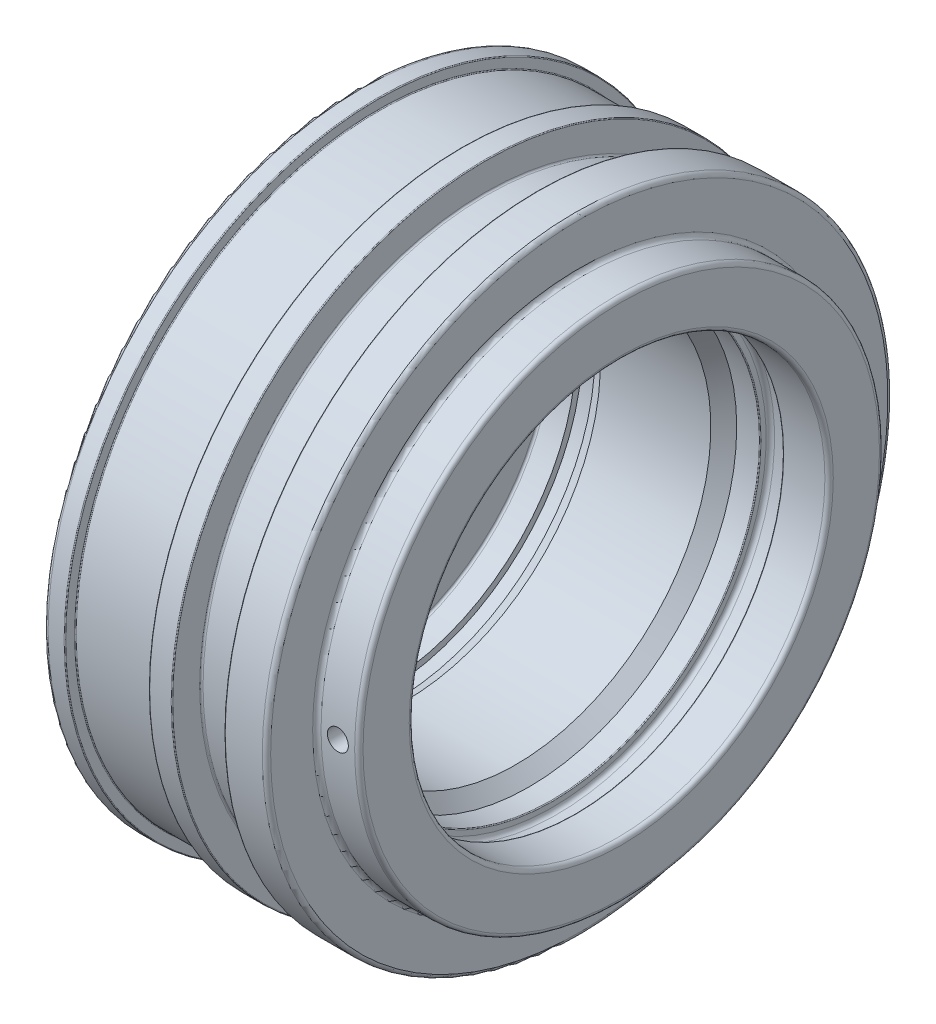
from build123d import *

# Parameters (mm, degrees)
SKETCH2_R          = 2.5
M6_GEVINDHUL_DEPTH = 75.5000001


with BuildPart() as part:
    # Sketch1 → Base-Revolve (revolve)
    with BuildSketch(Plane.XY):
        with BuildLine():
            Line((15, 62.520567051), (15, 73.5))
            ThreePointArc((15, 73.5), (15.292893219, 74.207106781), (16, 74.5))
            Line((16, 74.5), (19.8, 74.5))
            ThreePointArc((19.8, 74.5), (19.941421356, 74.441421356), (20, 74.3))
            Line((20, 74.3), (20, 72.2))
            ThreePointArc((20, 72.2), (20.058578644, 72.058578644), (20.2, 72))
            Line((20.2, 72), (39.8, 72))
            ThreePointArc((39.8, 72), (39.941421356, 72.058578644), (40, 72.2))
            Line((40, 72.2), (40, 74.3))
            ThreePointArc((40, 74.3), (40.058578644, 74.441421356), (40.2, 74.5))
            Line((40.2, 74.5), (45.3, 74.5))
            ThreePointArc((45.3, 74.5), (45.441421356, 74.441421356), (45.5, 74.3))
            Line((45.5, 74.3), (45.5, 67.9))
            ThreePointArc((45.5, 67.9), (45.617157288, 67.617157288), (45.9, 67.5))
            Line((45.9, 67.5), (57.6, 67.5))
            ThreePointArc((57.6, 67.5), (57.882842712, 67.617157288), (58, 67.9))
            Line((58, 67.9), (58, 74.3))
            ThreePointArc((58, 74.3), (58.058578644, 74.441421356), (58.2, 74.5))
            Line((58.2, 74.5), (67, 74.5))
            ThreePointArc((67, 74.5), (67.707106781, 74.207106781), (68, 73.5))
            Line((68, 73.5), (68, 63.5))
            ThreePointArc((68, 63.5), (68.292893219, 62.792893219), (69, 62.5))
            Line((69, 62.5), (77, 62.5))
            ThreePointArc((77, 62.5), (77.707106781, 62.207106781), (78, 61.5))
            Line((78, 61.5), (78, 50.5))
            ThreePointArc((78, 50.5), (77.707106781, 49.792893219), (77, 49.5))
            Line((77, 49.5), (67.2, 49.5))
            ThreePointArc((67.2, 49.5), (67.058578644, 49.558578644), (67, 49.7))
            Line((67, 49.7), (67, 50.9))
            ThreePointArc((67, 50.9), (66.707106781, 51.607106781), (66, 51.9))
            Line((66, 51.9), (62.6, 51.9))
            ThreePointArc((62.6, 51.9), (61.892893219, 51.607106781), (61.6, 50.9))
            Line((61.6, 50.9), (61.6, 49.7))
            ThreePointArc((61.6, 49.7), (61.541421356, 49.558578644), (61.4, 49.5))
            Line((61.4, 49.5), (56, 49.5))
            Line((56, 49.5), (52.9175, 46.4175))
            Line((52.9175, 46.4175), (26.615178499, 46.4175))
            Line((26.615178499, 46.4175), (24, 47.75))
            Line((24, 47.75), (21, 47.75))
            Line((21, 47.75), (21, 46.25))
            Line((21, 46.25), (15.5, 46.25))
            ThreePointArc((15.5, 46.25), (15.146446609, 46.103553391), (15, 45.75))
            Line((15, 45.75), (15, 32.5))
            Line((15, 32.5), (20, 18.762612903))
            Line((20, 18.762612903), (20, 0))
            Line((20, 0), (0, 0))
            Line((0, 0), (0, 51.496886927))
            Line((0, 51.496886927), (14.573576436, 61.701415006))
            ThreePointArc((14.573576436, 61.701415006), (14.887010833, 62.058818437), (15, 62.520567051))
        make_face()
    revolve(axis=Axis((-64.519784768, 0, 0), (1, 0, 0)))

    # Sketch2 → M6 gevindhul (cut, through all)
    with BuildSketch(Plane.XY):
        with Locations((73, 0)):
            Circle(SKETCH2_R)
    extrude(amount=M6_GEVINDHUL_DEPTH, mode=Mode.SUBTRACT)


solid = part.part
